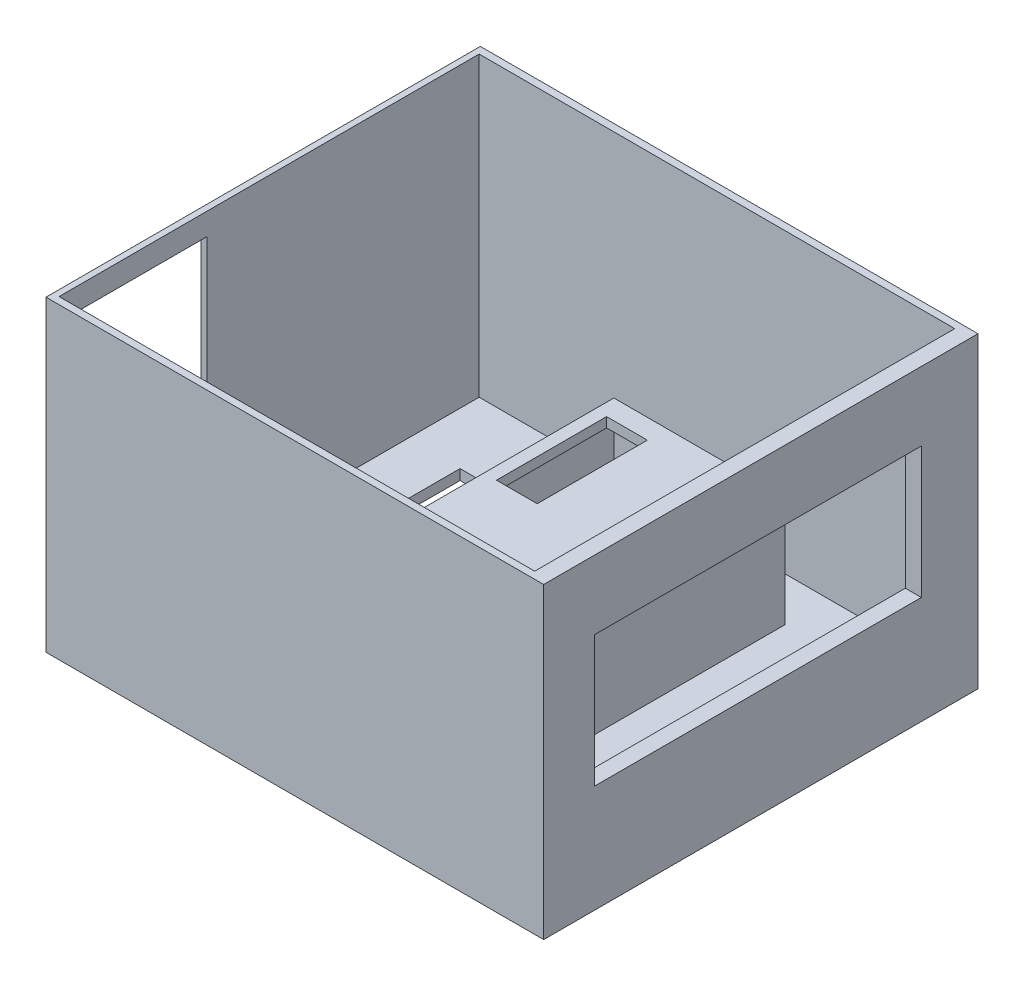
from build123d import *

# Parameters (mm, degrees)
SKETCH1_W           = 144
SKETCH1_H           = 125.68
BOSS_EXTRUDE1_DEPTH = 3
SKETCH2_W           = 144
SKETCH2_H           = 125.68
SKETCH2_W_2         = 137.62694519
SKETCH2_H_2         = 121.548177757
BOSS_EXTRUDE2_DEPTH = 86
SKETCH4_W           = 94.55727782
SKETCH4_H           = 37.953937335
CUT_EXTRUDE1_DEPTH  = 20
SKETCH6_W           = 39.790164022
SKETCH6_H           = 75.651590962
CUT_EXTRUDE3_DEPTH  = 20
SKETCH8_W           = 49.5692413
SKETCH8_H           = 91.849069086
BOSS_EXTRUDE3_DEPTH = 32
SKETCH7_W           = 45
SKETCH7_H           = 87.31
CUT_EXTRUDE4_DEPTH  = 32.17
SKETCH9_W           = 11.79717637
SKETCH9_H           = 31.86635219
CUT_EXTRUDE5_DEPTH  = 40
SKETCH10_W          = 11.687827299
SKETCH10_H          = 31.429738741
CUT_EXTRUDE6_DEPTH  = 40
SKETCH11_W          = 16.650134538
SKETCH11_H          = 74.314635754
SKETCH11_W_2        = 24.505886262
CUT_EXTRUDE7_DEPTH  = 40


with BuildPart() as part:
    # Sketch1 → Boss-Extrude1 (new body)
    with BuildSketch(Plane(origin=(0, 0, 0), x_dir=(1, 0, 0), z_dir=(0, 1, 0))):
        with Locations((-0.900426333, 18.508659662)):
            Rectangle(SKETCH1_W, SKETCH1_H)
    extrude(amount=BOSS_EXTRUDE1_DEPTH)

    # Sketch2 → Boss-Extrude2 (add)
    with BuildSketch(Plane(origin=(0, 3, 0), x_dir=(1, 0, 0), z_dir=(0, 1, 0))):
        with Locations((-0.900426333, 18.508659662)):
            Rectangle(SKETCH2_W, SKETCH2_H)
        with Locations((-2.339827632, 18.478566742)):
            Rectangle(SKETCH2_W_2, SKETCH2_H_2, mode=Mode.SUBTRACT)
    extrude(amount=BOSS_EXTRUDE2_DEPTH)

    # Sketch4 → Cut-Extrude1 (cut)
    with BuildSketch(Plane(origin=(71.099573667, 0, 0), x_dir=(0, 0, -1), z_dir=(1, 0, 0))):
        with Locations((17.672764627, 50.079604952)):
            Rectangle(SKETCH4_W, SKETCH4_H)
    extrude(amount=-CUT_EXTRUDE1_DEPTH, mode=Mode.SUBTRACT)

    # Sketch6 → Cut-Extrude3 (cut)
    with BuildSketch(Plane.ZY.offset(72.900426333)):
        with Locations((19.353212204, 44.793227562)):
            Rectangle(SKETCH6_W, SKETCH6_H)
    extrude(amount=-CUT_EXTRUDE3_DEPTH, mode=Mode.SUBTRACT)

    # Sketch8 → Boss-Extrude3 (add)
    with BuildSketch(Plane(origin=(0, 3, 0), x_dir=(1, 0, 0), z_dir=(0, 1, 0))):
        with Locations((5.315093732, 20.62475692)):
            Rectangle(SKETCH8_W, SKETCH8_H)
    extrude(amount=BOSS_EXTRUDE3_DEPTH)

    # Sketch7 → Cut-Extrude4 (cut)
    with BuildSketch(Plane.XZ):
        with Locations((5.233997278, -20.691377503)):
            Rectangle(SKETCH7_W, SKETCH7_H)
    extrude(amount=-CUT_EXTRUDE4_DEPTH, mode=Mode.SUBTRACT)

    # Sketch9 → Cut-Extrude5 (cut)
    with BuildSketch(Plane.XZ.offset(-32.17)):
        with Locations((-9.959298471, -44.905011983)):
            Rectangle(SKETCH9_W, SKETCH9_H)
    extrude(amount=-CUT_EXTRUDE5_DEPTH, mode=Mode.SUBTRACT)

    # Sketch10 → Cut-Extrude6 (cut)
    with BuildSketch(Plane.XZ.offset(-32.17)):
        with Locations((19.967671673, 4.341983418)):
            Rectangle(SKETCH10_W, SKETCH10_H)
    extrude(amount=-CUT_EXTRUDE6_DEPTH, mode=Mode.SUBTRACT)

    # Sketch11 → Cut-Extrude7 (cut)
    with BuildSketch(Plane.XZ):
        with Locations((50.891184892, -21.453909531)):
            Rectangle(SKETCH11_W, SKETCH11_H)
        with Locations((-43.781754887, -21.453909531)):
            Rectangle(SKETCH11_W_2, SKETCH11_H)
    extrude(amount=-CUT_EXTRUDE7_DEPTH, mode=Mode.SUBTRACT)


solid = part.part
